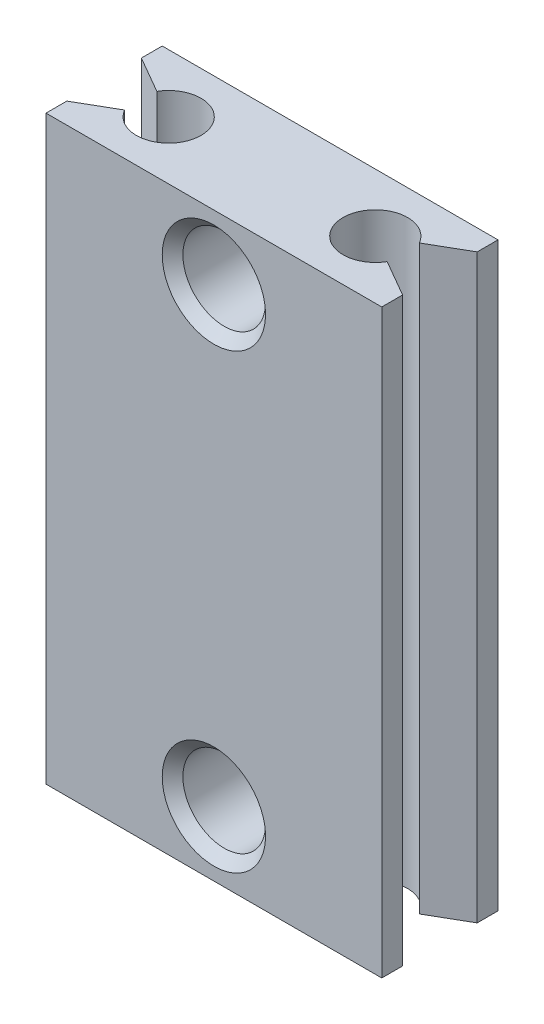
from build123d import *

# Parameters (mm, degrees)
BASE_SKETCH_W                 = 13
BASE_SKETCH_H                 = 4.5
BLOCK_SIZE_DEPTH              = 22.5
M3_CLEARANCE_HOLE1_AT_2_COUNT = 2
M3_CLEARANCE_HOLE1_AT_2_PITCH = 17.5
M3X0_5_TAPPED_HOLE1_D         = 2.5
SIDE_CUTS_DEPTH               = 23.5


with BuildPart() as part:
    # Base Sketch → Block Size (new body)
    with BuildSketch(Plane(origin=(0, 0, 0), x_dir=(1, 0, 0), z_dir=(0, 1, 0))):
        with Locations((0, -2.25)):
            Rectangle(BASE_SKETCH_W, BASE_SKETCH_H)
    extrude(amount=BLOCK_SIZE_DEPTH)

    # Sketch3 → M3 Clearance Hole1 (revolve, cut)
    with BuildSketch(Plane(origin=(0, 20, 0), x_dir=(0, 1, 0), z_dir=(1, 0, 0))):
        Polygon((0, 0), (0, 4.5), (2, 4.5), (1.6, 4.1), (1.6, 0.4), (2, 0), align=None)
    m3_clearance_hole1 = revolve(axis=Axis((0, 20, -6.35), (0, 0, 1)), mode=Mode.SUBTRACT)

    # M3 Clearance Hole1 at 2: M3 Clearance Hole1 ×2
    with Locations(*[(0, -i * M3_CLEARANCE_HOLE1_AT_2_PITCH, 0) for i in range(1, M3_CLEARANCE_HOLE1_AT_2_COUNT)]):
        add(m3_clearance_hole1, mode=Mode.SUBTRACT)

    # M3x0.5 Tapped Hole1 (through all)
    with Locations(Plane.XZ):
        with Locations((-3.999999936, 2.25), (3.999999936, 2.25)):
            Hole(M3X0_5_TAPPED_HOLE1_D / 2)

    # Sketch6 → Side Cuts (cut, through all)
    with BuildSketch(Plane(origin=(0, 0, 0), x_dir=(1, 0, 0), z_dir=(0, 1, 0))):
        Polygon((-6.5, -0.80662429), (-3.999999936, -2.25), (-6.5, -3.69337571), align=None)
        Polygon((3.999999936, -2.25), (6.5, -0.80662429), (6.5, -3.69337571), align=None)
    extrude(amount=SIDE_CUTS_DEPTH, mode=Mode.SUBTRACT)


solid = part.part
